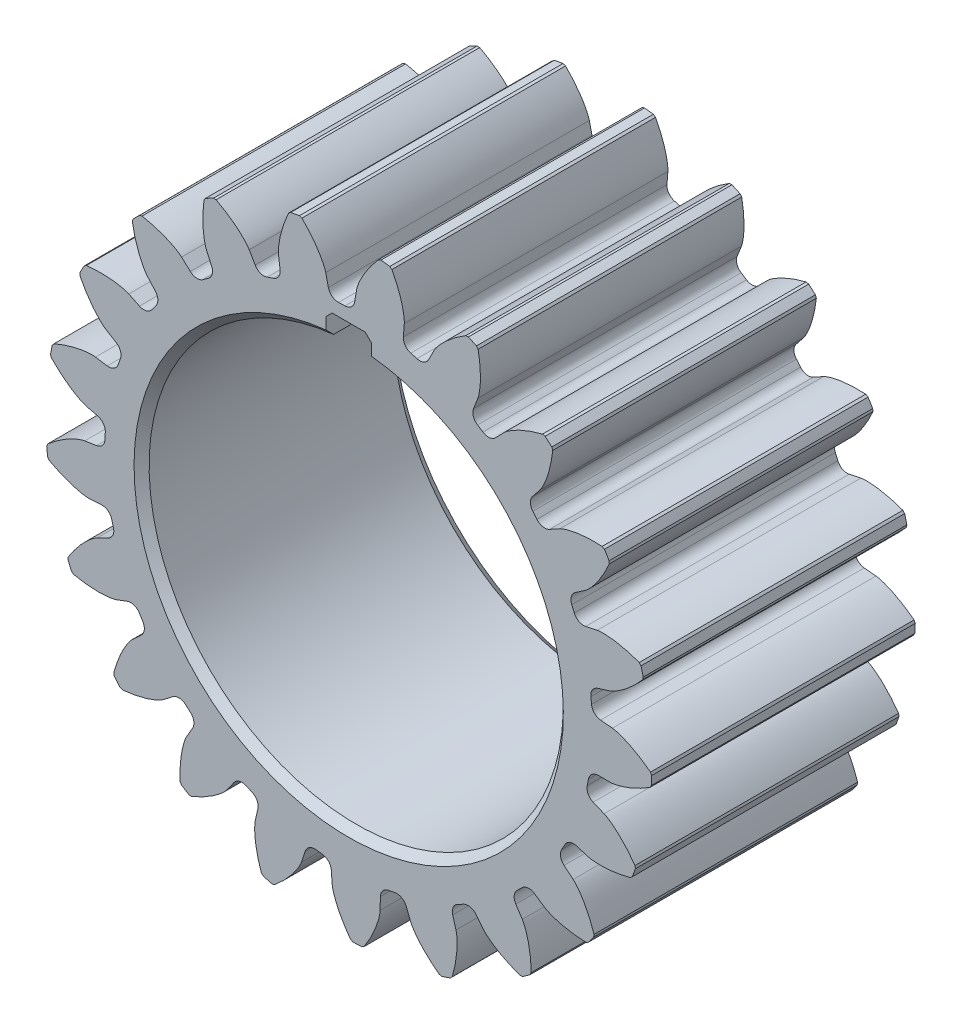
from build123d import *

# Parameters (mm, degrees)
SKETCH1_R                    = 32.375
BOSS_EXTRUDE1_DEPTH          = 35
BOSS_EXTRUDE3_DEPTH          = 35
CHAMFER2_SIZE                = 0.2
CIRPATTERN3_COUNT            = 21
CHAMFER2_OF_CIRPATTERN3_SIZE = 0.2
CUT_EXTRUDE1_DEPTH           = 35
CHAMFER3_SIZE                = 1.6
CHAMFER4_SIZE                = 1
CHAMFER5_SIZE                = 0.8


with BuildPart() as part:
    # Sketch1 → Boss-Extrude1 (new body)
    with BuildSketch(Plane.XY):
        Circle(SKETCH1_R)
    extrude(amount=BOSS_EXTRUDE1_DEPTH)

    # Sketch2 → Boss-Extrude3 (add)
    with BuildSketch(Plane.XY):
        with BuildLine():
            Line((34.721544782, -4.800143049), (33.142847964, -4.800143049))
            ThreePointArc((33.142847964, -4.800143049), (32.292207356, -5.107738748), (31.835030495, -5.888247477))
            ThreePointArc((31.835030495, -5.888247477), (32.340175659, -1.501220617), (32.243615811, 2.913737198))
            ThreePointArc((32.243615811, 2.913737198), (32.626520543, 2.09423215), (33.445007549, 1.709156081))
            Line((33.445007549, 1.709156081), (35.016915486, 1.562906016))
            add(Edge.make_bspline(
                [(35.016915486, 1.562906016), (35.029373185, 1.561746953), (35.064259518, 1.557924834), (35.129985256, 1.548444428), (35.236824963, 1.529782438), (35.37229189, 1.50132217), (35.54650171, 1.459180688), (35.750474094, 1.40267249), (35.973180493, 1.333411198), (36.213758171, 1.250369619), (36.452135886, 1.160755701), (36.688301531, 1.065096076), (36.922021779, 0.964173504), (37.203200127, 0.835312117), (37.537600604, 0.671626437), (37.924143581, 0.4670682), (38.357214518, 0.219537755), (38.792480907, -0.049144347), (39.21563066, -0.326950929), (39.634504235, -0.621202633), (39.934647089, -0.842343619), (40.136719507, -0.997860889), (40.235636377, -1.075204782)],
                knots=[0, 0, 0, 0, 0, 0.005376749, 0.015083688, 0.02853182, 0.04661014, 0.064854849, 0.092110525, 0.119476176, 0.146842496, 0.174208854, 0.201574956, 0.228941013, 0.256307345, 0.307035032, 0.361767352, 0.416499661, 0.471231937, 0.525964282, 0.580696616, 0.634207508, 0.634207508, 0.634207508, 0.634207508, 0.634207508], degree=4))
            ThreePointArc((40.235636377, -1.075204782), (40.206704873, -1.866382388), (40.162217474, -2.656837894))
            add(Edge.make_bspline(
                [(34.721544782, -4.800143049), (34.734056285, -4.800143049), (34.769146675, -4.799569227), (34.835468036, -4.796218405), (34.943577141, -4.787534271), (35.08109807, -4.771746011), (35.25846271, -4.745924503), (35.466792855, -4.708555257), (35.694957896, -4.660223273), (35.942193967, -4.599825852), (36.187848395, -4.532680552), (36.431860338, -4.459310617), (36.673924959, -4.380473827), (36.965831838, -4.278214873), (37.313958089, -4.146211865), (37.717789036, -3.978342533), (38.171928792, -3.771996125), (38.630214041, -3.544792404), (39.07728005, -3.307380959), (39.521611742, -3.053198969), (39.840950334, -2.860814114), (40.056560858, -2.724685551), (40.162217474, -2.656837894)],
                knots=[0, 0, 0, 0, 0, 0.005376749, 0.015083688, 0.02853182, 0.04661014, 0.064854849, 0.092110525, 0.119476176, 0.146842496, 0.174208854, 0.201574956, 0.228941013, 0.256307345, 0.307035032, 0.361767352, 0.416499661, 0.471231937, 0.525964282, 0.580696616, 0.634207508, 0.634207508, 0.634207508, 0.634207508, 0.634207508], degree=4))
        make_face()
    boss_extrude3 = extrude(amount=BOSS_EXTRUDE3_DEPTH)

    # Chamfer2
    chamfer2_edges = [part.edges().sort_by_distance(p)[0] for p in [
        (40.162217474, -2.656837894, 17.5),
        (40.235636377, -1.075204782, 17.5),
    ]]
    chamfer(chamfer2_edges, length=CHAMFER2_SIZE)

    # CirPattern3: Boss-Extrude3 ×21 about axis
    cirpattern3_axis = Axis((0, 0, 35), (0, 0, -1))
    for i in range(1, CIRPATTERN3_COUNT):
        add(boss_extrude3.rotate(cirpattern3_axis, i * 360 / CIRPATTERN3_COUNT))

    # Chamfer2 of CirPattern3
    chamfer2_of_cirpattern3_edges = [part.edges().sort_by_distance(p)[0] for p in [
        (37.594806121, -14.376823457, 17.5),
        (38.131157772, -12.887098468, 17.5),
        (31.686931262, -24.819365165, 17.5),
        (32.638558464, -23.553916902, 17.5),
        (22.963533505, -33.056597359, 17.5),
        (24.245880004, -32.127866453, 17.5),
        (12.199725022, -38.356605812, 17.5),
        (13.698848704, -37.84711408, 17.5),
        (0.351917434, -40.248461512, 17.5),
        (1.934614581, -40.203479531, 17.5),
        (-11.527159563, -38.564064781, 17.5),
        (-10.001518538, -38.987589396, 17.5),
        (-22.381997847, -33.453081657, 17.5),
        (-21.048972844, -34.307480849, 17.5),
        (-31.2480974, -25.369645422, 17.5),
        (-30.226133541, -26.579002073, 17.5),
        (-37.33766637, -15.032004859, 17.5),
        (-36.717569627, -16.488862322, 17.5),
        (-40.109619828, -3.358704697, 17.5),
        (-39.94648852, -4.933614794, 17.5),
        (-39.317657547, 8.613031117, 17.5),
        (-39.625986605, 7.06000606, 17.5),
        (-35.03214885, 19.819461319, 17.5),
        (-35.784541885, 18.426314392, 17.5),
        (-27.633879991, 29.264845406, 17.5),
        (-28.76348358, 28.155363829, 17.5),
        (-17.780219627, 36.109919552, 17.5),
        (-19.186663533, 35.382685631, 17.5),
        (-6.346708721, 39.74646888, 17.5),
        (-7.905024232, 39.466100541, 17.5),
        (5.650735107, 39.851370023, 17.5),
        (4.079011163, 40.042779223, 17.5),
        (17.146086323, 36.415302056, 17.5),
        (15.700608516, 37.061481247, 17.5),
        (27.117932525, 29.743574694, 17.5),
        (25.927137901, 30.78710802, 17.5),
        (34.680231416, 20.429000194, 17.5),
        (33.849927304, 21.777165139, 17.5),
        (39.161039555, 9.299219375, 17.5),
        (38.765002119, 10.832225567, 17.5),
    ]]
    chamfer(chamfer2_of_cirpattern3_edges, length=CHAMFER2_OF_CIRPATTERN3_SIZE)

    # Sketch3 → Cut-Extrude1 (cut)
    with BuildSketch(Plane.XY):
        with BuildLine():
            Line((3, 27.335873866), (3, 30.7))
            Line((3, 30.7), (-3, 30.7))
            Line((-3, 30.7), (-3, 27.335873866))
            ThreePointArc((-3, 27.335873866), (0, -27.5), (3, 27.335873866))
        make_face()
    extrude(amount=CUT_EXTRUDE1_DEPTH, mode=Mode.SUBTRACT)

    # Chamfer3
    chamfer3_edges = [part.edges().sort_by_distance(p)[0] for p in [
        (0, -27.5, 0),
    ]]
    chamfer(chamfer3_edges, length=CHAMFER3_SIZE)

    # Chamfer4
    chamfer4_edges = [part.edges().sort_by_distance(p)[0] for p in [
        (0, -27.5, 35),
    ]]
    chamfer(chamfer4_edges, length=CHAMFER4_SIZE)

    # Chamfer5
    chamfer5_edges = [part.edges().sort_by_distance(p)[0] for p in [
        (3, 30.7, 17.5),
        (-3, 30.7, 17.5),
    ]]
    chamfer(chamfer5_edges, length=CHAMFER5_SIZE)


solid = part.part
